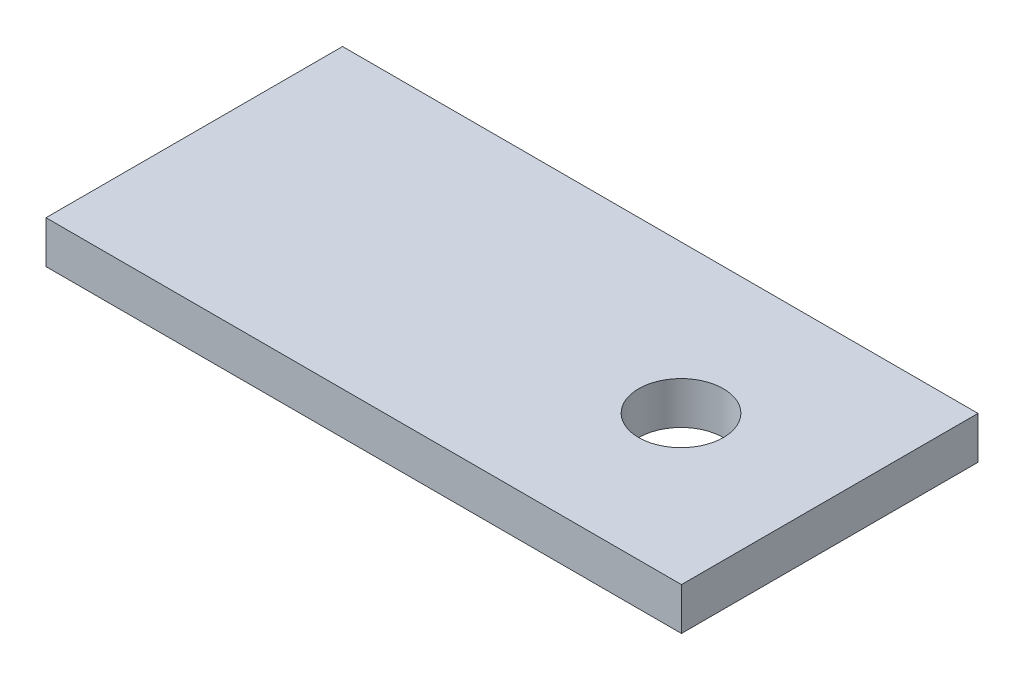
from build123d import *

# Parameters (mm, degrees)
SKETCH1_W                = 30
SKETCH1_H                = 14
BOSS_EXTRUDE1_DEPTH      = 2
CUT_EXTRUDE10_DEPTH      = 34.166247904
CUT_EXTRUDE10_DEPTH_BACK = 34.166247904
SKETCH1_9_OUTSIDE_W      = 38.634
SKETCH1_9_OUTSIDE_H      = 22.634
SKETCH1_9_OUTSIDE_W_2    = 30
SKETCH1_9_OUTSIDE_H_2    = 14
SKETCH1_9_OUTSIDE_R      = 2


with BuildPart() as part:
    # Sketch1 → Boss-Extrude1 (new body)
    with BuildSketch(Plane(origin=(0, 0, 0), x_dir=(1, 0, 0), z_dir=(0, 1, 0))):
        with Locations((-15, 7)):
            Rectangle(SKETCH1_W, SKETCH1_H)
    extrude(amount=BOSS_EXTRUDE1_DEPTH)

    # Sketch1_9 outside → Cut-Extrude10 (cut, two sides: drawn at the far end of the back side and taken through both)
    # profile 1 of 2: a face of its own
    with BuildSketch(Plane(origin=(0, 0, 0), x_dir=(1, 0, 0), z_dir=(0, 1, 0)).offset(-CUT_EXTRUDE10_DEPTH_BACK)):
        with Locations((-15, 7)):
            Rectangle(SKETCH1_9_OUTSIDE_W, SKETCH1_9_OUTSIDE_H)
        with Locations((-15, 7)):
            Rectangle(SKETCH1_9_OUTSIDE_W_2, SKETCH1_9_OUTSIDE_H_2, mode=Mode.SUBTRACT)
    # profile 2 of 2: a face of its own
    with BuildSketch(Plane(origin=(0, 0, 0), x_dir=(1, 0, 0), z_dir=(0, 1, 0)).offset(-CUT_EXTRUDE10_DEPTH_BACK)):
        with Locations((-7.020370045, 7)):
            Circle(SKETCH1_9_OUTSIDE_R)
    extrude(amount=CUT_EXTRUDE10_DEPTH + CUT_EXTRUDE10_DEPTH_BACK, mode=Mode.SUBTRACT)


solid = part.part
